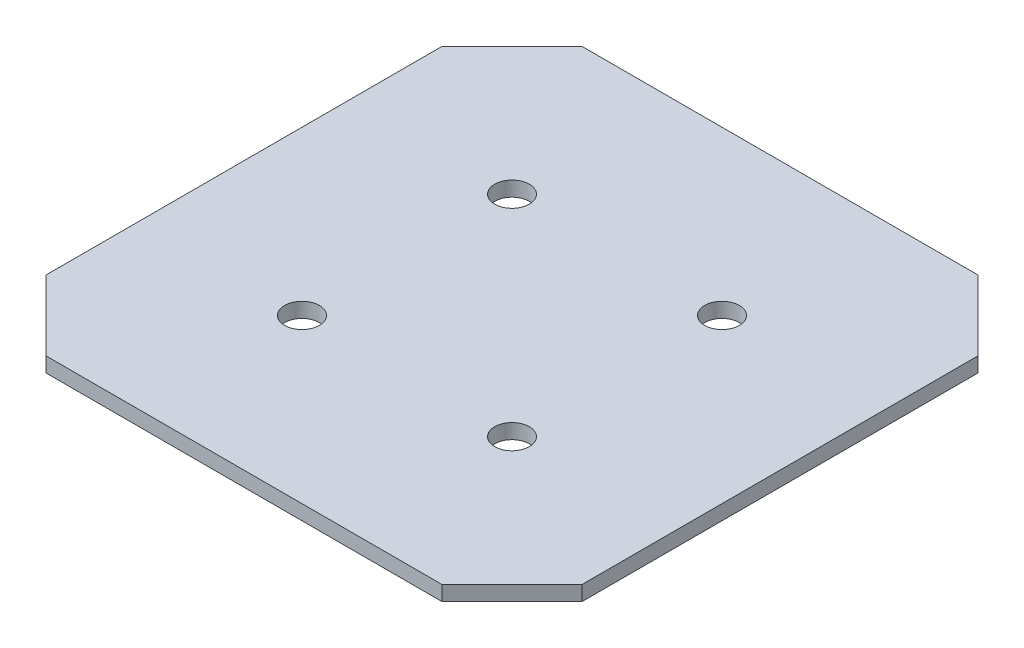
from build123d import *

# Parameters (mm, degrees)
SKETCH1_R           = 3.5
BOSS_EXTRUDE1_DEPTH = 3


with BuildPart() as part:
    # Sketch1 → Boss-Extrude1 (new body)
    with BuildSketch(Plane(origin=(0, 0, 0), x_dir=(1, 0, 0), z_dir=(0, 1, 0))):
        Polygon((-54.142135624, 40), (-40, 54.142135624), (40, 54.142135624), (54.142135624, 40), (54.142135624, -40), (40, -54.142135624), (-40, -54.142135624), (-54.142135624, -40), align=None)
        with Locations((-21.213203436, 21.213203436)):
            Circle(SKETCH1_R, mode=Mode.SUBTRACT)
        with Locations((21.213203436, 21.213203436)):
            Circle(SKETCH1_R, mode=Mode.SUBTRACT)
        with Locations((21.213203436, -21.213203436)):
            Circle(SKETCH1_R, mode=Mode.SUBTRACT)
        with Locations((-21.213203436, -21.213203436)):
            Circle(SKETCH1_R, mode=Mode.SUBTRACT)
    extrude(amount=BOSS_EXTRUDE1_DEPTH)


solid = part.part
